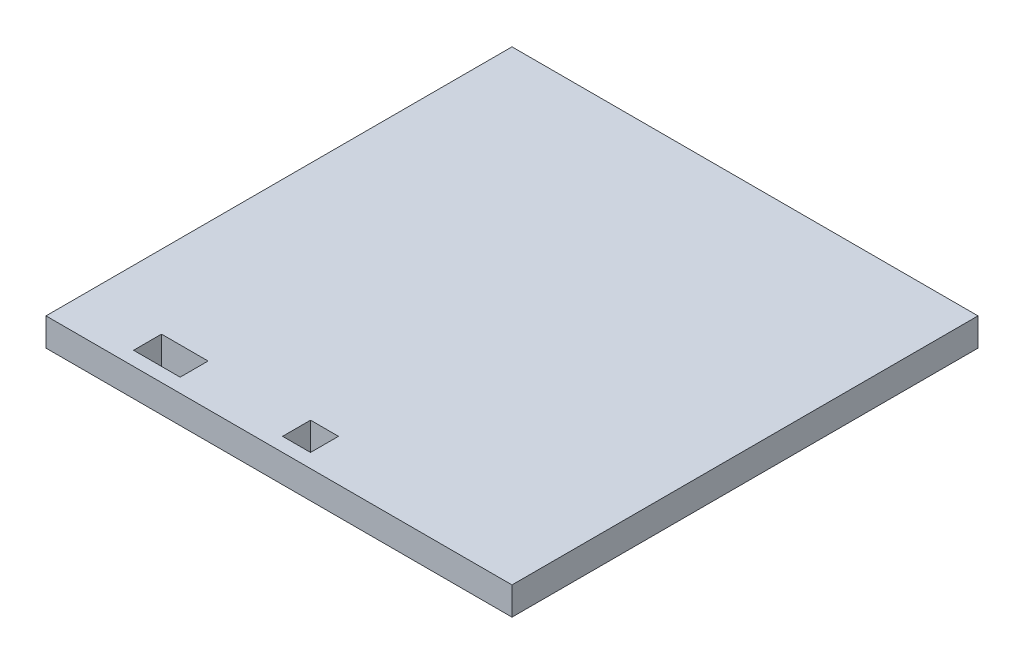
from build123d import *

# Parameters (mm, degrees)
SKETCH1_W                = 100
SKETCH1_H                = 100
BOSS_EXTRUDE1_DEPTH      = 6
SKETCH6_W                = 6
SKETCH6_H                = 6
CUT_EXTRUDE1_DEPTH       = 4
CUT_EXTRUDE1_DEPTH_BACK  = 4
SKETCH62_W               = 10
SKETCH62_H               = 6
CUT_EXTRUDE12_DEPTH      = 4
CUT_EXTRUDE12_DEPTH_BACK = 4


with BuildPart() as part:
    # Sketch1 → Boss-Extrude1 (new body)
    with BuildSketch(Plane(origin=(0, 0, 0), x_dir=(1, 0, 0), z_dir=(0, 1, 0))):
        Rectangle(SKETCH1_W, SKETCH1_H)
    extrude(amount=BOSS_EXTRUDE1_DEPTH)

    # Sketch6 → Cut-Extrude1 (cut, two sides)
    with BuildSketch(Plane(origin=(0, 3, 0), x_dir=(1, 0, 0), z_dir=(0, 1, 0))) as cut_extrude1_sk:
        with Locations((0.767778608, -44)):
            Rectangle(SKETCH6_W, SKETCH6_H)
    extrude(amount=CUT_EXTRUDE1_DEPTH, mode=Mode.SUBTRACT)
    extrude(cut_extrude1_sk.sketch, amount=-CUT_EXTRUDE1_DEPTH_BACK, mode=Mode.SUBTRACT)

    # Sketch62 → Cut-Extrude12 (cut, two sides)
    with BuildSketch(Plane(origin=(-28.445435161, 3, 88), x_dir=(-1, 0, 0), z_dir=(0, 1, 0))) as cut_extrude12_sk:
        with Locations((0.767778608, -44)):
            Rectangle(SKETCH62_W, SKETCH62_H)
    extrude(amount=CUT_EXTRUDE12_DEPTH, mode=Mode.SUBTRACT)
    extrude(cut_extrude12_sk.sketch, amount=-CUT_EXTRUDE12_DEPTH_BACK, mode=Mode.SUBTRACT)


solid = part.part
